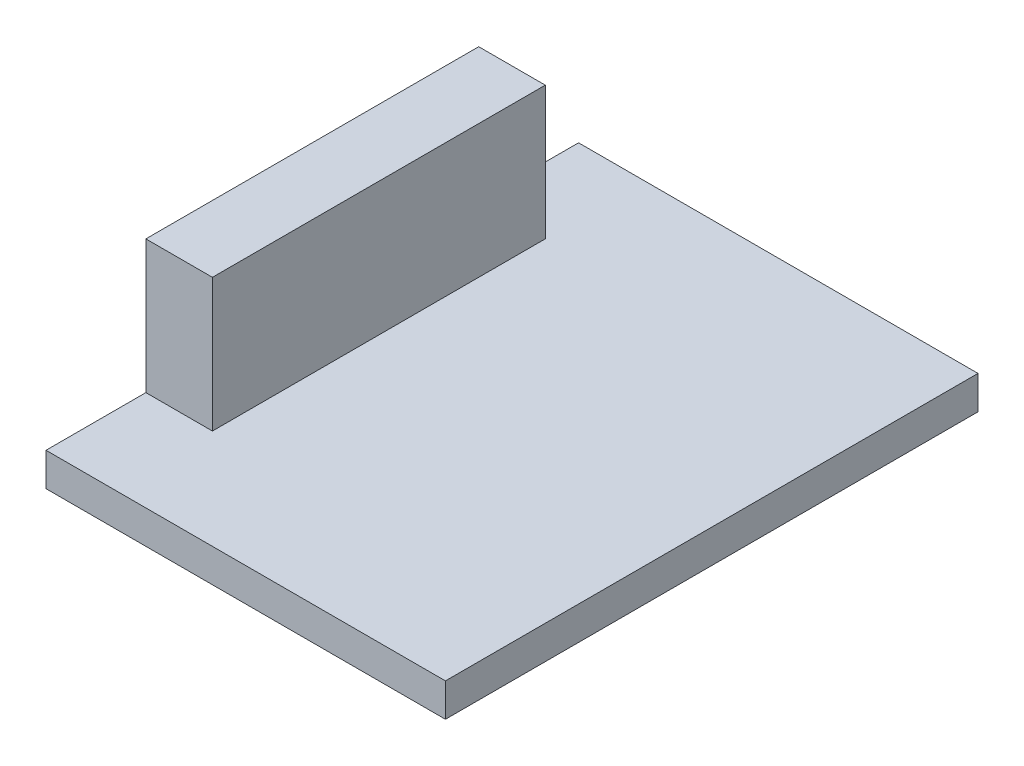
from build123d import *

# Parameters (mm, degrees)
SKETCH1_W           = 19.05
SKETCH1_H           = 25.4
BOSS_EXTRUDE1_DEPTH = 1.5875
SKETCH2_W           = 3.175
SKETCH2_H           = 15.875
BOSS_EXTRUDE2_DEPTH = 6.35


with BuildPart() as part:
    # Sketch1 → Boss-Extrude1 (new body)
    with BuildSketch(Plane(origin=(0, 0, 0), x_dir=(1, 0, 0), z_dir=(0, 1, 0))):
        with Locations((9.525, 12.7)):
            Rectangle(SKETCH1_W, SKETCH1_H)
    extrude(amount=BOSS_EXTRUDE1_DEPTH)

    # Sketch2 → Boss-Extrude2 (add)
    with BuildSketch(Plane(origin=(0, 1.5875, 0), x_dir=(1, 0, 0), z_dir=(0, 1, 0))):
        with Locations((1.5875, 12.7)):
            Rectangle(SKETCH2_W, SKETCH2_H)
    extrude(amount=BOSS_EXTRUDE2_DEPTH)


solid = part.part
